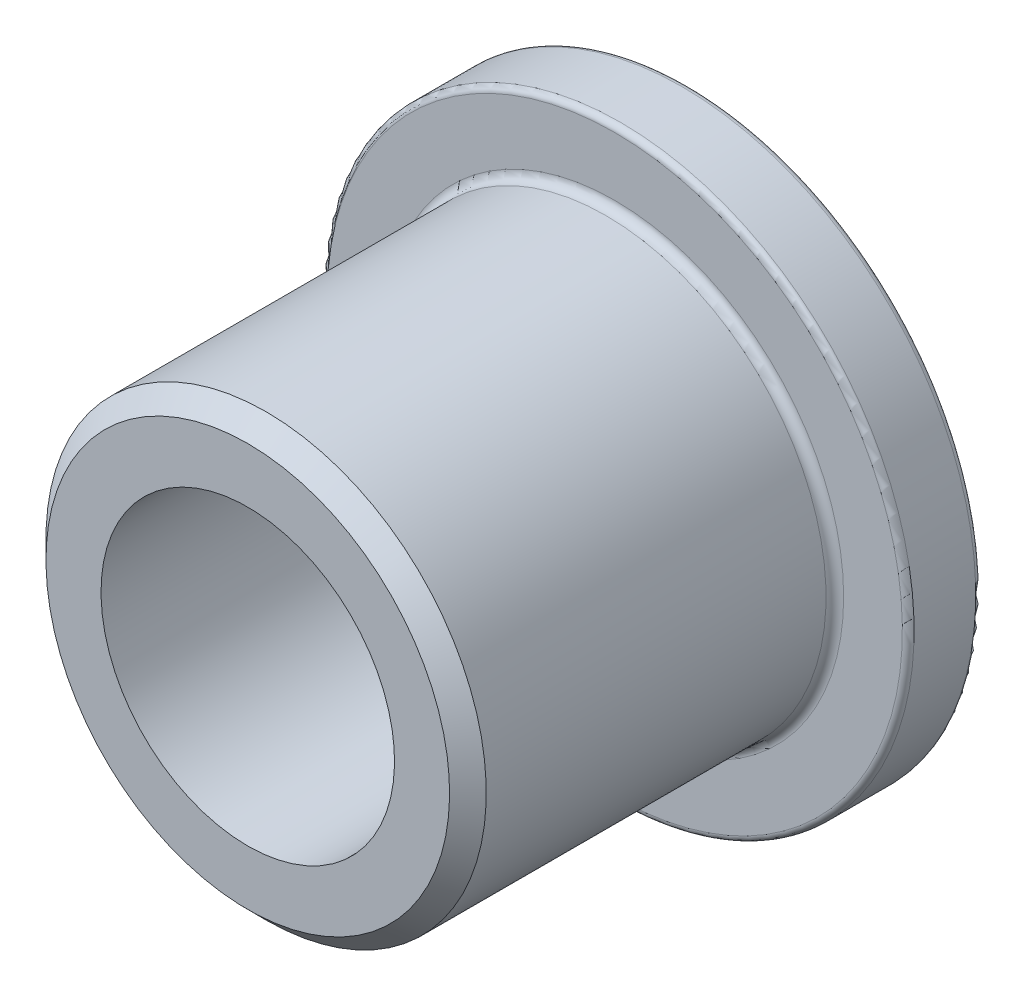
from build123d import *

# Parameters (mm, degrees)
CHAMFER1_SIZE = 0.396875
FILLET1_R     = 0.1905
FILLET2_R     = 0.127
CHAMFER2_SIZE = 0.3175


with BuildPart() as part:
    # Sketch3 → Revolve1 (revolve)
    with BuildSketch(Plane(origin=(0, 0, 0), x_dir=(0, 0, -1), z_dir=(1, 0, 0)), mode=Mode.PRIVATE) as revolve1_sk:
        Polygon((-4.7625, 3.175), (4.7625, 3.175), (4.7625, 6.35), (3.175, 6.35), (3.175, 4.7625), (-4.7625, 4.7625), align=None)
    revolve(revolve1_sk.sketch.rotate(Axis((0, 0, 4.7625), (0, 0, -1)), 180), axis=Axis((0, 0, 4.7625), (0, 0, -1)))

    # Chamfer1
    chamfer1_edges = [part.edges().sort_by_distance(p)[0] for p in [
        (0, 4.7625, 4.7625),
    ]]
    chamfer(chamfer1_edges, length=CHAMFER1_SIZE)

    # Fillet1
    fillet1_edges = [part.edges().sort_by_distance(p)[0] for p in [
        (0, 4.7625, -3.175),
    ]]
    fillet(fillet1_edges, radius=FILLET1_R)

    # Fillet2
    fillet2_edges = [part.edges().sort_by_distance(p)[0] for p in [
        (0, 6.35, -3.175),
        (0, 6.35, -4.7625),
    ]]
    fillet(fillet2_edges, radius=FILLET2_R)

    # Chamfer2
    chamfer2_edges = [part.edges().sort_by_distance(p)[0] for p in [
        (0, 3.175, -4.7625),
    ]]
    chamfer(chamfer2_edges, length=CHAMFER2_SIZE)


solid = part.part
